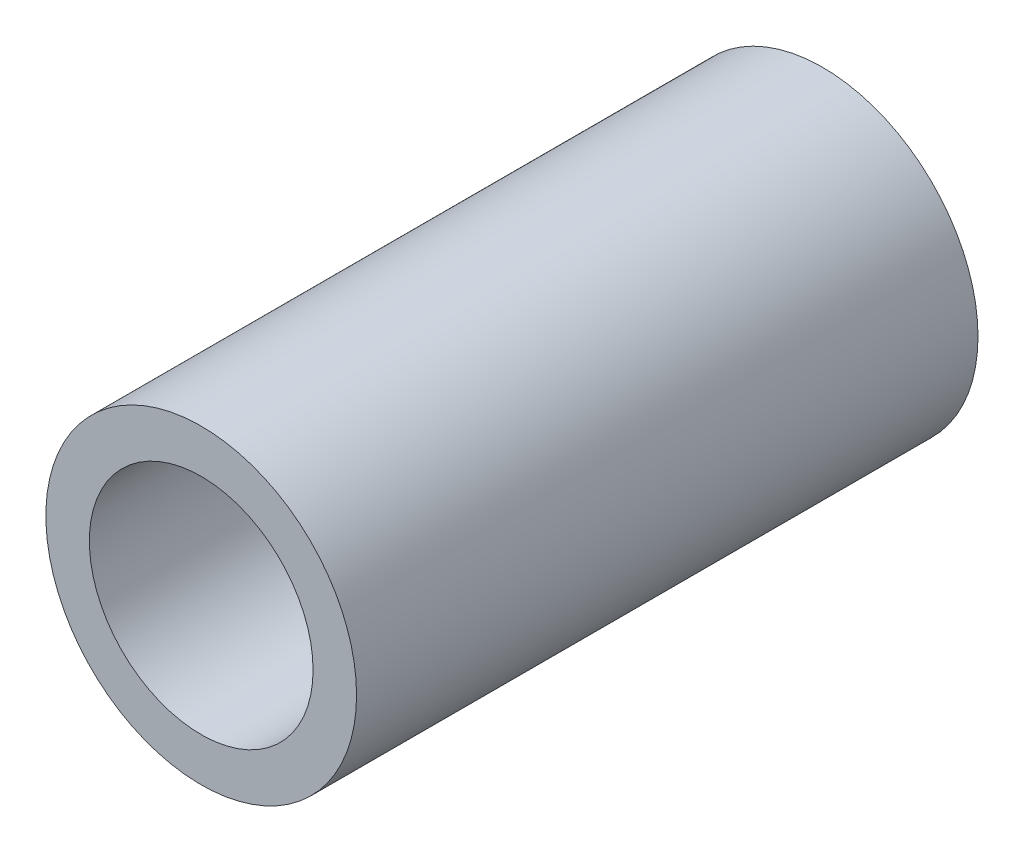
from build123d import *

# Parameters (mm, degrees)
SKETCH1_R      = 1.5875
SKETCH1_R_2    = 1.143
EXTRUDE1_DEPTH = 3.175


with BuildPart() as part:
    # Sketch1 → Extrude1 (new body, symmetric)
    with BuildSketch(Plane.XY):
        Circle(SKETCH1_R)
        Circle(SKETCH1_R_2, mode=Mode.SUBTRACT)
    extrude(amount=EXTRUDE1_DEPTH, both=True)


solid = part.part
